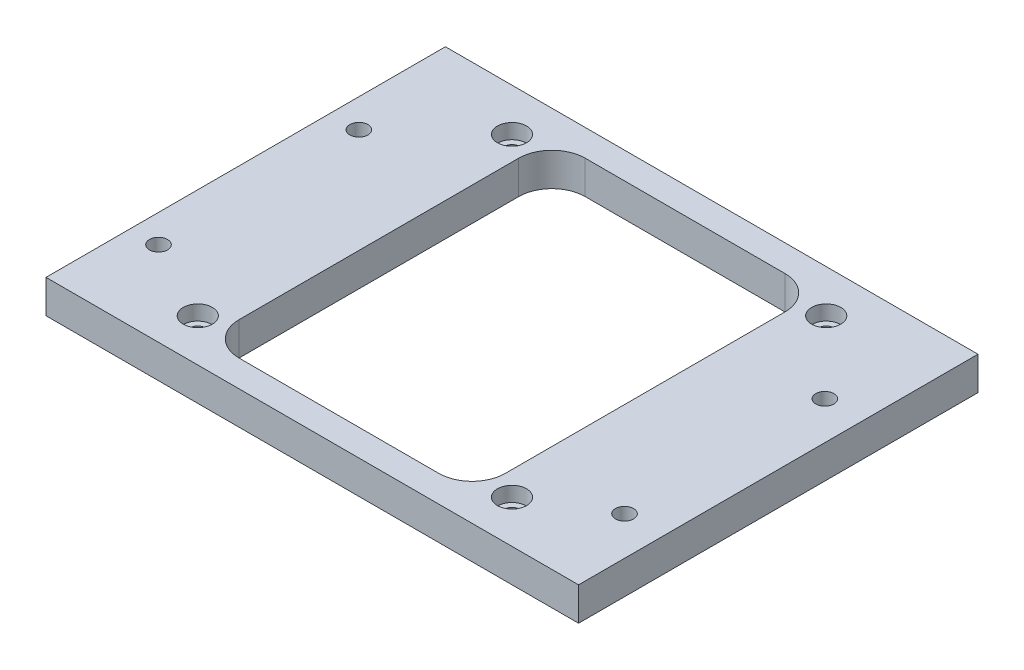
from build123d import *

# Parameters (mm, degrees)
SKETCH2_W                                      = 101.6
SKETCH2_H                                      = 76.2
BOSS_EXTRUDE1_DEPTH                            = 6.35
CBORE_FOR_4_SOCKET_HEAD_CAP_SCREW1_D           = 3.2639
CBORE_FOR_4_SOCKET_HEAD_CAP_SCREW1_CBORE_D     = 5.55752
CBORE_FOR_4_SOCKET_HEAD_CAP_SCREW1_CBORE_DEPTH = 2.8448
F_8_32_TAPPED_HOLE1_D                          = 3.4544


with BuildPart() as part:
    # Sketch2 → Boss-Extrude1 (new body)
    with BuildSketch(Plane(origin=(0, 0, 0), x_dir=(1, 0, 0), z_dir=(0, 1, 0))):
        Rectangle(SKETCH2_W, SKETCH2_H)
        with BuildLine():
            Line((-19.05, 33.02), (19.05, 33.02))
            ThreePointArc((19.05, 33.02), (23.540128061, 31.160128061), (25.4, 26.67))
            Line((25.4, 26.67), (25.4, -26.67))
            ThreePointArc((25.4, -26.67), (23.540128061, -31.160128061), (19.05, -33.02))
            Line((19.05, -33.02), (-19.05, -33.02))
            ThreePointArc((-19.05, -33.02), (-23.540128061, -31.160128061), (-25.4, -26.67))
            Line((-25.4, -26.67), (-25.4, 26.67))
            ThreePointArc((-25.4, 26.67), (-23.540128061, 31.160128061), (-19.05, 33.02))
        make_face(mode=Mode.SUBTRACT)
    extrude(amount=BOSS_EXTRUDE1_DEPTH)

    # CBORE for #4 Socket Head Cap Screw1 (through all)
    with Locations(Plane(origin=(0, 6.35, 0), x_dir=(1, 0, 0), z_dir=(0, 1, 0))):
        with Locations((-29.972, 29.972), (29.972, 29.972), (29.972, -29.972), (-29.972, -29.972)):
            CounterBoreHole(CBORE_FOR_4_SOCKET_HEAD_CAP_SCREW1_D / 2, CBORE_FOR_4_SOCKET_HEAD_CAP_SCREW1_CBORE_D / 2, CBORE_FOR_4_SOCKET_HEAD_CAP_SCREW1_CBORE_DEPTH)

    # #8-32 Tapped Hole1 (through all)
    with Locations(Plane(origin=(0, 6.35, 0), x_dir=(1, 0, 0), z_dir=(0, 1, 0))):
        with Locations((-45.339, 16.129), (-45.466, -21.971), (43.561, 16.129), (43.434, -21.971)):
            Hole(F_8_32_TAPPED_HOLE1_D / 2)


solid = part.part
